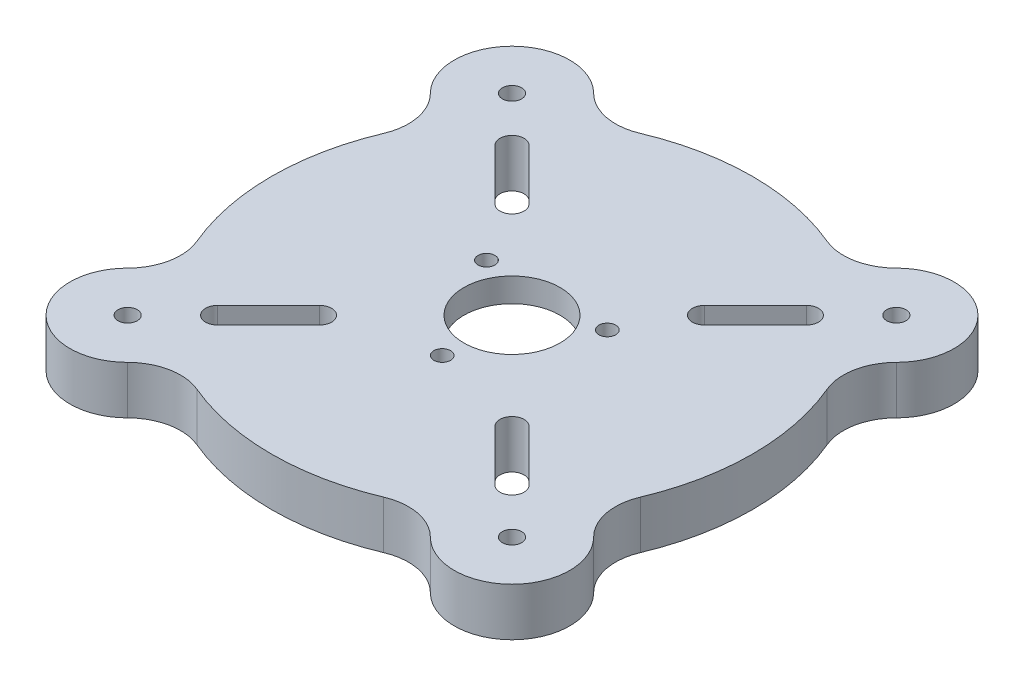
from build123d import *

# Parameters (mm, degrees)
SZKIC1_R                    = 2
DODANIE_WYCI_GNI_CIE1_DEPTH = 10
SZKIC2_R                    = 21.25
SZKIC2_R_2                  = 1.75
SZKIC2_R_3                  = 10
WYTNIJ_WYCI_GNI_CIE3_DEPTH  = 5
SZKIC2_8_R                  = 1.75
SZKIC2_8_R_2                = 10
WYTNIJ_WYCI_GNI_CIE6_DEPTH  = 75.1479844


with BuildPart() as part:
    # Szkic1 → Dodanie-wyci_gni_cie1 (new body)
    with BuildSketch(Plane(origin=(0, 0, 0), x_dir=(1, 0, 0), z_dir=(0, 1, 0))):
        with BuildLine():
            ThreePointArc((46.077281732, -19.413503243), (50, 0), (46.077281732, 19.413503243))
            ThreePointArc((46.077281732, 19.413503243), (45.41900176, 25.799706685), (48.436814511, 31.466251763))
            ThreePointArc((48.436814511, 31.466251763), (48.436814511, 48.436814511), (31.466251763, 48.436814511))
            ThreePointArc((31.466251763, 48.436814511), (25.799706685, 45.41900176), (19.413503243, 46.077281732))
            ThreePointArc((19.413503243, 46.077281732), (0, 50), (-19.413503243, 46.077281732))
            ThreePointArc((-19.413503243, 46.077281732), (-25.799706685, 45.41900176), (-31.466251763, 48.436814511))
            ThreePointArc((-31.466251763, 48.436814511), (-48.436814511, 48.436814511), (-48.436814511, 31.466251763))
            ThreePointArc((-48.436814511, 31.466251763), (-45.41900176, 25.799706685), (-46.077281732, 19.413503243))
            ThreePointArc((-46.077281732, 19.413503243), (-50, 0), (-46.077281732, -19.413503243))
            ThreePointArc((-46.077281732, -19.413503243), (-45.41900176, -25.799706685), (-48.436814511, -31.466251763))
            ThreePointArc((-48.436814511, -31.466251763), (-48.436814511, -48.436814511), (-31.466251763, -48.436814511))
            ThreePointArc((-31.466251763, -48.436814511), (-25.799706685, -45.41900176), (-19.413503243, -46.077281732))
            ThreePointArc((-19.413503243, -46.077281732), (0, -50), (19.413503243, -46.077281732))
            ThreePointArc((19.413503243, -46.077281732), (25.799706685, -45.41900176), (31.466251763, -48.436814511))
            ThreePointArc((31.466251763, -48.436814511), (48.436814511, -48.436814511), (48.436814511, -31.466251763))
            ThreePointArc((48.436814511, -31.466251763), (45.41900176, -25.799706685), (46.077281732, -19.413503243))
        make_face()
        with BuildLine():
            ThreePointArc((-21.767766953, -18.232233047), (-18.232233047, -18.232233047), (-18.232233047, -21.767766953))
            Line((-18.232233047, -21.767766953), (-28.838834765, -32.374368671))
            ThreePointArc((-28.838834765, -32.374368671), (-32.374368671, -32.374368671), (-32.374368671, -28.838834765))
            Line((-32.374368671, -28.838834765), (-21.767766953, -18.232233047))
        make_face(mode=Mode.SUBTRACT)
        with BuildLine():
            ThreePointArc((18.232233047, -21.767766953), (18.232233047, -18.232233047), (21.767766953, -18.232233047))
            Line((21.767766953, -18.232233047), (32.374368671, -28.838834765))
            ThreePointArc((32.374368671, -28.838834765), (32.374368671, -32.374368671), (28.838834765, -32.374368671))
            Line((28.838834765, -32.374368671), (18.232233047, -21.767766953))
        make_face(mode=Mode.SUBTRACT)
        with BuildLine():
            ThreePointArc((-18.232233047, 21.767766953), (-18.232233047, 18.232233047), (-21.767766953, 18.232233047))
            Line((-21.767766953, 18.232233047), (-32.374368671, 28.838834765))
            ThreePointArc((-32.374368671, 28.838834765), (-32.374368671, 32.374368671), (-28.838834765, 32.374368671))
            Line((-28.838834765, 32.374368671), (-18.232233047, 21.767766953))
        make_face(mode=Mode.SUBTRACT)
        with BuildLine():
            ThreePointArc((21.767766953, 18.232233047), (18.232233047, 18.232233047), (18.232233047, 21.767766953))
            Line((18.232233047, 21.767766953), (28.838834765, 32.374368671))
            ThreePointArc((28.838834765, 32.374368671), (32.374368671, 32.374368671), (32.374368671, 28.838834765))
            Line((32.374368671, 28.838834765), (21.767766953, 18.232233047))
        make_face(mode=Mode.SUBTRACT)
        with Locations((39.951533137, -39.951533137)):
            Circle(SZKIC1_R, mode=Mode.SUBTRACT)
        with Locations((-39.951533137, -39.951533137)):
            Circle(SZKIC1_R, mode=Mode.SUBTRACT)
        with Locations((-39.951533137, 39.951533137)):
            Circle(SZKIC1_R, mode=Mode.SUBTRACT)
        with Locations((39.951533137, 39.951533137)):
            Circle(SZKIC1_R, mode=Mode.SUBTRACT)
    extrude(amount=DODANIE_WYCI_GNI_CIE1_DEPTH)

    # Szkic2 → Wytnij-wyci_gni_cie3 (cut)
    with BuildSketch(Plane.XZ):
        Circle(SZKIC2_R)
        with Locations((0, 14.5)):
            Circle(SZKIC2_R_2, mode=Mode.SUBTRACT)
        with Locations((12.558868355, -7.249133975)):
            Circle(SZKIC2_R_2, mode=Mode.SUBTRACT)
        with Locations((-12.555868355, -7.250866025)):
            Circle(SZKIC2_R_2, mode=Mode.SUBTRACT)
        Circle(SZKIC2_R_3, mode=Mode.SUBTRACT)
    extrude(amount=-WYTNIJ_WYCI_GNI_CIE3_DEPTH, mode=Mode.SUBTRACT)

    # Szkic2_8 → Wytnij-wyci_gni_cie6 (cut, through all)
    with BuildSketch(Plane.XZ):
        with Locations((0, 14.5)):
            Circle(SZKIC2_8_R)
        with Locations((12.558868355, -7.249133975)):
            Circle(SZKIC2_8_R)
        with Locations((-12.555868355, -7.250866025)):
            Circle(SZKIC2_8_R)
        Circle(SZKIC2_8_R_2)
    extrude(amount=-WYTNIJ_WYCI_GNI_CIE6_DEPTH, mode=Mode.SUBTRACT)


solid = part.part
